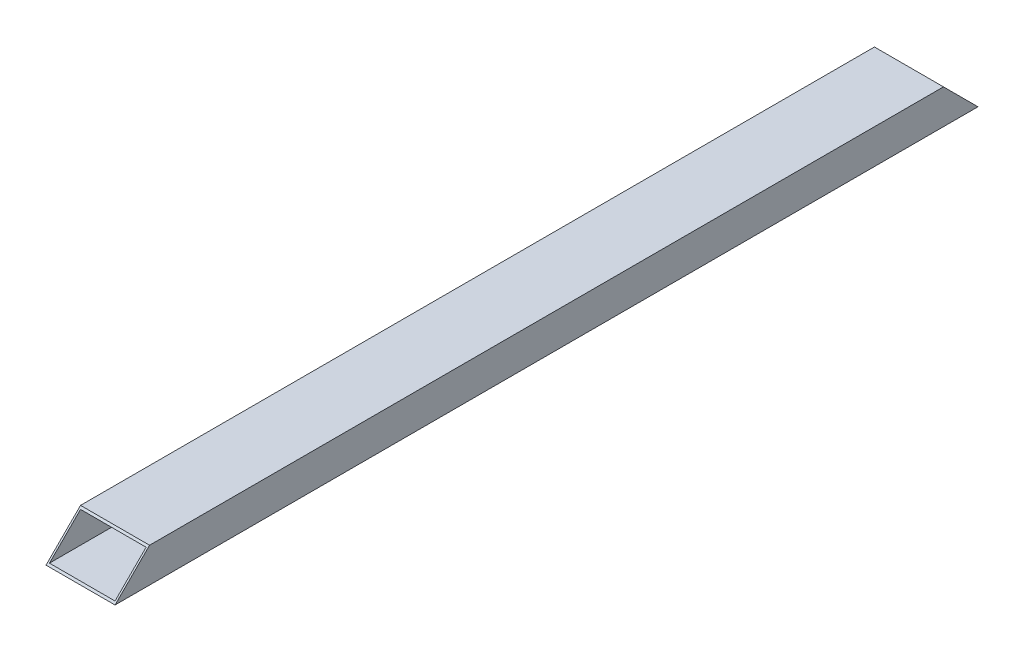
from build123d import *

# Parameters (mm, degrees)
SKETCH1_W           = 40
SKETCH1_H           = 20
BOSS_EXTRUDE1_DEPTH = 500
SKETCH3_W           = 38
SKETCH3_H           = 18
CUT_EXTRUDE1_DEPTH  = 501
CUT_EXTRUDE2_DEPTH  = 41


with BuildPart() as part:
    # Sketch1 → Boss-Extrude1 (new body)
    with BuildSketch(Plane.XY):
        with Locations((0, 2)):
            Rectangle(SKETCH1_W, SKETCH1_H)
    extrude(amount=BOSS_EXTRUDE1_DEPTH)

    # Sketch3 → Cut-Extrude1 (cut, through all)
    with BuildSketch(Plane.XY.offset(500)):
        with Locations((0, 2)):
            Rectangle(SKETCH3_W, SKETCH3_H)
    extrude(amount=-CUT_EXTRUDE1_DEPTH, mode=Mode.SUBTRACT)

    # Sketch4 → Cut-Extrude2 (cut, through all)
    with BuildSketch(Plane(origin=(20, 0, 0), x_dir=(0, 0, -1), z_dir=(1, 0, 0))):
        Polygon((-500, 12), (-480, 12), (-500, -8), align=None)
        Polygon((0, 12), (-20, 12), (0, -8), align=None)
    extrude(amount=-CUT_EXTRUDE2_DEPTH, mode=Mode.SUBTRACT)


solid = part.part
